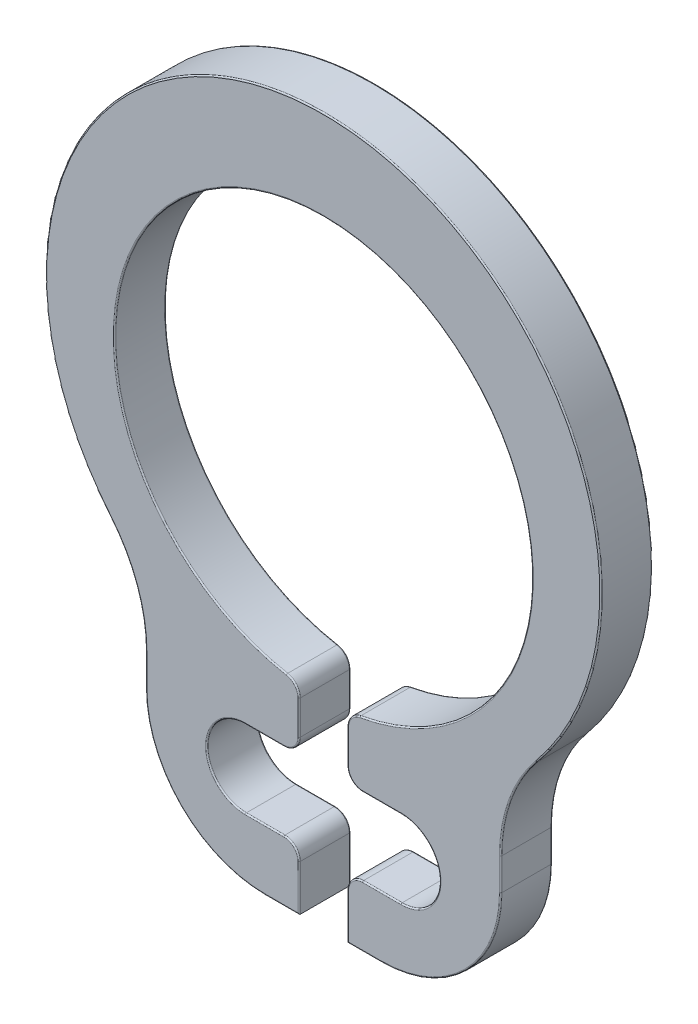
from build123d import *

# Parameters (mm, degrees)
SKETCH3_R                    = 3.25
BOSS_EXTRUDE1_DEPTH          = 0.4
SKETCH4_W                    = 0.75
SKETCH4_H                    = 6.35
CUT_EXTRUDE_THIN1_DEPTH      = 1.4
CUT_EXTRUDE_THIN1_DEPTH_BACK = 1.4
FILLET2_R                    = 0.2375
FILLET1_R                    = 0.02


with BuildPart() as part:
    # Sketch3 → Boss-Extrude1 (new body, symmetric)
    with BuildSketch(Plane.XY):
        with BuildLine():
            Line((2.7625, -3.142776093), (2.7625, -3.64))
            ThreePointArc((2.7625, -3.64), (2.217718613, -4.955218613), (0.9025, -5.5))
            Line((0.9025, -5.5), (-0.9025, -5.5))
            ThreePointArc((-0.9025, -5.5), (-2.217718613, -4.955218613), (-2.7625, -3.64))
            Line((-2.7625, -3.64), (-2.7625, -3.142776093))
            ThreePointArc((-2.7625, -3.142776093), (-2.907039777, -2.31859199), (-3.323407965, -1.592776093))
            ThreePointArc((-3.323407965, -1.592776093), (0, 5.5), (3.323407965, -1.592776093))
            ThreePointArc((3.323407965, -1.592776093), (2.907039777, -2.31859199), (2.7625, -3.142776093))
        make_face()
        with Locations((0, 0.85)):
            Circle(SKETCH3_R, mode=Mode.SUBTRACT)
        with BuildLine():
            Line((-1.2125, -4.55), (1.2125, -4.55))
            ThreePointArc((1.2125, -4.55), (1.8125, -3.95), (1.2125, -3.35))
            Line((1.2125, -3.35), (-1.2125, -3.35))
            ThreePointArc((-1.2125, -3.35), (-1.8125, -3.95), (-1.2125, -4.55))
        make_face(mode=Mode.SUBTRACT)
    extrude(amount=BOSS_EXTRUDE1_DEPTH, both=True)

    # Sketch4 → Cut-Extrude-Thin1 (cut, two sides)
    with BuildSketch(Plane.XY) as cut_extrude_thin1_sk:
        with Locations((0, -2.325)):
            Rectangle(SKETCH4_W, SKETCH4_H)
    extrude(amount=CUT_EXTRUDE_THIN1_DEPTH, mode=Mode.SUBTRACT)
    extrude(cut_extrude_thin1_sk.sketch, amount=-CUT_EXTRUDE_THIN1_DEPTH_BACK, mode=Mode.SUBTRACT)

    # Fillet2
    fillet2_edges = [part.edges().sort_by_distance(p)[0] for p in [
        (0.375, -2.378292893, 0),
        (-0.375, -2.378292893, 0),
        (-0.375, -4.55, 0),
        (-0.375, -3.35, 0),
        (0.375, -4.55, 0),
        (0.375, -3.35, 0),
    ]]
    fillet(fillet2_edges, radius=FILLET2_R)

    # Fillet1
    fillet1_edges = [part.edges().sort_by_distance(p)[0] for p in [
        (-2.217718613, -4.955218613, 0.4),
        (-2.7625, -3.391388046, -0.4),
        (-2.907039777, -2.31859199, -0.4),
        (-0.63875, -5.5, 0.4),
        (2.217718613, -4.955218613, 0.4),
        (2.7625, -3.391388046, 0.4),
        (2.907039777, -2.31859199, 0.4),
        (-1.8125, -3.95, -0.4),
        (-0.9125, -4.55, -0.4),
        (1.8125, -3.95, -0.4),
        (0.9125, -3.35, -0.4),
        (0, 5.5, 0.4),
        (-1.8125, -3.95, 0.4),
        (-0.9125, -4.55, 0.4),
        (1.8125, -3.95, 0.4),
        (0.9125, -3.35, 0.4),
        (-2.907039777, -2.31859199, 0.4),
        (0.63875, -5.5, -0.4),
        (0.63875, -5.5, 0.4),
        (-2.7625, -3.391388046, 0.4),
        (0, 5.5, -0.4),
        (0.9125, -4.55, -0.4),
        (0.9125, -4.55, 0.4),
        (-0.375, -5.14375, 0.4),
        (-0.9125, -3.35, 0.4),
        (-0.375, -2.84789644, 0.4),
        (0, 4.1, 0.4),
        (0.375, -2.84789644, 0.4),
        (2.907039777, -2.31859199, -0.4),
        (0.375, -5.14375, 0.4),
        (-0.430411115, -2.43081374, 0.4),
        (-0.444562139, -3.280437861, 0.4),
        (0.430411115, -2.43081374, 0.4),
        (0.444562139, -3.280437861, 0.4),
        (-0.444562139, -4.619562139, 0.4),
        (0.444562139, -4.619562139, 0.4),
        (0.375, -5.14375, -0.4),
        (2.7625, -3.391388046, -0.4),
        (-0.375, -5.14375, -0.4),
        (0.375, -2.84789644, -0.4),
        (0, 4.1, -0.4),
        (-0.375, -2.84789644, -0.4),
        (-0.9125, -3.35, -0.4),
        (-0.430411115, -2.43081374, -0.4),
        (-0.444562139, -3.280437861, -0.4),
        (2.217718613, -4.955218613, -0.4),
        (0.430411115, -2.43081374, -0.4),
        (0.444562139, -3.280437861, -0.4),
        (-0.444562139, -4.619562139, -0.4),
        (0.444562139, -4.619562139, -0.4),
        (-0.63875, -5.5, -0.4),
        (-2.217718613, -4.955218613, -0.4),
    ]]
    fillet(fillet1_edges, radius=FILLET1_R)


solid = part.part
